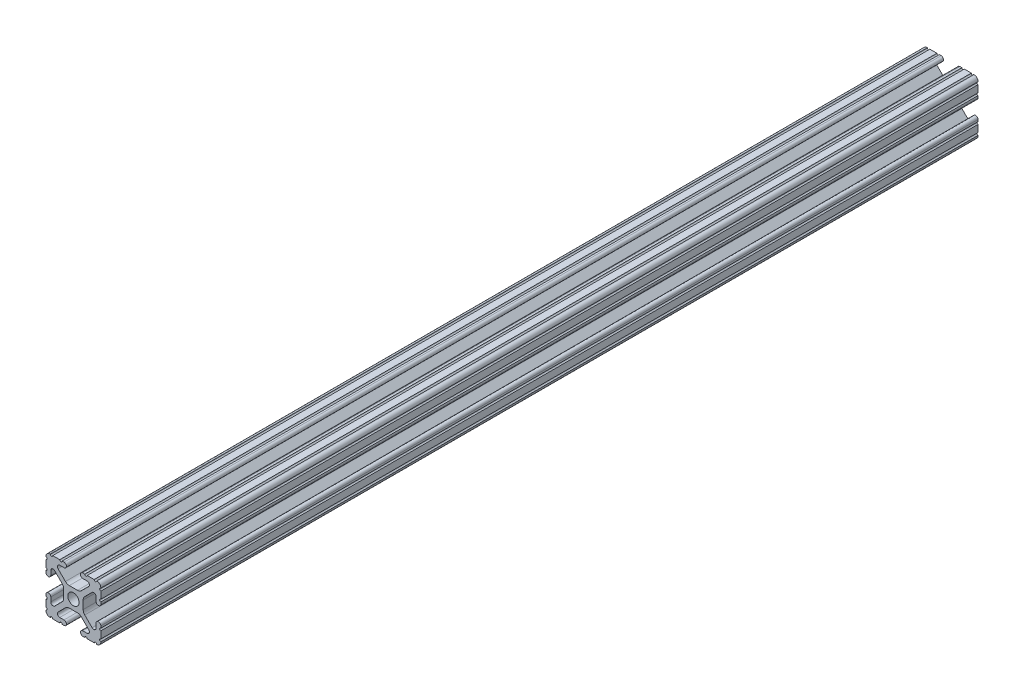
from build123d import *

# Parameters (mm, degrees)
SKETCH3_W                = 25.4
SKETCH3_H                = 25.4
BOSS_EXTRUDE1_DEPTH      = 203.2
BOSS_EXTRUDE1_DEPTH_BACK = 203.2
SKETCH4_R                = 2.6035
CUT_EXTRUDE1_DEPTH       = 407.4
CUT_EXTRUDE2_DEPTH       = 407.4
FILLET1_R                = 2.54
FILLET2_R                = 1.778


with BuildPart() as part:
    # Sketch3 → Boss-Extrude1 (new body, two sides)
    with BuildSketch(Plane.XY) as boss_extrude1_sk:
        Rectangle(SKETCH3_W, SKETCH3_H)
    extrude(amount=BOSS_EXTRUDE1_DEPTH)
    extrude(boss_extrude1_sk.sketch, amount=-BOSS_EXTRUDE1_DEPTH_BACK)

    # Sketch4 → Cut-Extrude1 (cut, through all)
    with BuildSketch(Plane.XY.offset(203.2)):
        with BuildLine():
            Line((3.2512, 12.7), (-3.2512, 12.7))
            Line((-3.2512, 12.7), (-3.2512, 10.4902))
            Line((-3.2512, 10.4902), (-6.348478019, 10.4902))
            ThreePointArc((-6.348478019, 10.4902), (-7.335478831, 9.830707141), (-7.103895736, 8.666460301))
            Line((-7.103895736, 8.666460301), (-2.958635435, 4.5212))
            Line((-2.958635435, 4.5212), (2.958635435, 4.5212))
            Line((2.958635435, 4.5212), (7.103895736, 8.666460301))
            ThreePointArc((7.103895736, 8.666460301), (7.335478831, 9.830707141), (6.348478019, 10.4902))
            Line((6.348478019, 10.4902), (3.2512, 10.4902))
            Line((3.2512, 10.4902), (3.2512, 12.7))
        make_face()
        with BuildLine():
            Line((12.7, -3.2512), (12.7, 3.2512))
            Line((12.7, 3.2512), (10.4902, 3.2512))
            Line((10.4902, 3.2512), (10.4902, 6.348478019))
            ThreePointArc((10.4902, 6.348478019), (9.830707141, 7.335478831), (8.666460301, 7.103895736))
            Line((8.666460301, 7.103895736), (4.5212, 2.958635435))
            Line((4.5212, 2.958635435), (4.5212, -2.958635435))
            Line((4.5212, -2.958635435), (8.666460301, -7.103895736))
            ThreePointArc((8.666460301, -7.103895736), (9.830707141, -7.335478831), (10.4902, -6.348478019))
            Line((10.4902, -6.348478019), (10.4902, -3.2512))
            Line((10.4902, -3.2512), (12.7, -3.2512))
        make_face()
        with BuildLine():
            Line((-3.2512, -10.4902), (-3.2512, -12.7))
            Line((-3.2512, -12.7), (3.2512, -12.7))
            Line((3.2512, -12.7), (3.2512, -10.4902))
            Line((3.2512, -10.4902), (6.348478019, -10.4902))
            ThreePointArc((6.348478019, -10.4902), (7.335478831, -9.830707141), (7.103895736, -8.666460301))
            Line((7.103895736, -8.666460301), (2.958635435, -4.5212))
            Line((2.958635435, -4.5212), (-2.958635435, -4.5212))
            Line((-2.958635435, -4.5212), (-7.103895736, -8.666460301))
            ThreePointArc((-7.103895736, -8.666460301), (-7.335478831, -9.830707141), (-6.348478019, -10.4902))
            Line((-6.348478019, -10.4902), (-3.2512, -10.4902))
        make_face()
        with BuildLine():
            Line((-10.4902, 3.2512), (-12.7, 3.2512))
            Line((-12.7, 3.2512), (-12.7, -3.2512))
            Line((-12.7, -3.2512), (-10.4902, -3.2512))
            Line((-10.4902, -3.2512), (-10.4902, -6.348478019))
            ThreePointArc((-10.4902, -6.348478019), (-9.830707141, -7.335478831), (-8.666460301, -7.103895736))
            Line((-8.666460301, -7.103895736), (-4.5212, -2.958635435))
            Line((-4.5212, -2.958635435), (-4.5212, 2.958635435))
            Line((-4.5212, 2.958635435), (-8.666460301, 7.103895736))
            ThreePointArc((-8.666460301, 7.103895736), (-9.830707141, 7.335478831), (-10.4902, 6.348478019))
            Line((-10.4902, 6.348478019), (-10.4902, 3.2512))
        make_face()
        Circle(SKETCH4_R)
    extrude(amount=-CUT_EXTRUDE1_DEPTH, mode=Mode.SUBTRACT)

    # Sketch5 → Cut-Extrude2 (cut, through all)
    with BuildSketch(Plane.XY.offset(203.2)):
        with BuildLine():
            ThreePointArc((-11.5951, 3.2512), (-12.376382283, 3.574817717), (-12.7, 4.3561))
            Line((-12.7, 4.3561), (-12.7, 3.2512))
            Line((-12.7, 3.2512), (-11.5951, 3.2512))
        make_face()
        with BuildLine():
            ThreePointArc((-10.4902, 4.3561), (-10.813817717, 3.574817717), (-11.5951, 3.2512))
            Line((-11.5951, 3.2512), (-10.4902, 3.2512))
            Line((-10.4902, 3.2512), (-10.4902, 4.3561))
        make_face()
        with BuildLine():
            Line((-12.7, -3.2512), (-12.7, -4.3561))
            ThreePointArc((-12.7, -4.3561), (-12.376382283, -3.574817717), (-11.5951, -3.2512))
            Line((-11.5951, -3.2512), (-12.7, -3.2512))
        make_face()
        with BuildLine():
            Line((-10.4902, -3.2512), (-11.5951, -3.2512))
            ThreePointArc((-11.5951, -3.2512), (-10.813817717, -3.574817717), (-10.4902, -4.3561))
            Line((-10.4902, -4.3561), (-10.4902, -3.2512))
        make_face()
        with BuildLine():
            Line((-3.2512, -11.595100007), (-3.2512, -10.4902))
            Line((-3.2512, -10.4902), (-4.3561, -10.4902))
            ThreePointArc((-4.3561, -10.4902), (-3.574817715, -10.81381772), (-3.2512, -11.595100007))
        make_face()
        with BuildLine():
            Line((-3.2512, -12.7), (-3.2512, -11.595100007))
            ThreePointArc((-3.2512, -11.595100007), (-3.57481772, -12.376382285), (-4.3561, -12.7))
            Line((-4.3561, -12.7), (-3.2512, -12.7))
        make_face()
        with BuildLine():
            Line((3.2512, -10.4902), (3.2512, -11.5951))
            ThreePointArc((3.2512, -11.5951), (3.574817718, -10.813817717), (4.3561, -10.4902))
            Line((4.3561, -10.4902), (3.2512, -10.4902))
        make_face()
        with BuildLine():
            Line((3.2512, -12.7), (4.3561, -12.7))
            ThreePointArc((4.3561, -12.7), (3.574817717, -12.376382282), (3.2512, -11.5951))
            Line((3.2512, -11.5951), (3.2512, -12.7))
        make_face()
        with BuildLine():
            Line((11.5951, -3.2512), (10.4902, -3.2512))
            Line((10.4902, -3.2512), (10.4902, -4.3561))
            ThreePointArc((10.4902, -4.3561), (10.813817717, -3.574817717), (11.5951, -3.2512))
        make_face()
        with BuildLine():
            Line((12.7, -3.2512), (11.5951, -3.2512))
            ThreePointArc((11.5951, -3.2512), (12.376382283, -3.574817717), (12.7, -4.3561))
            Line((12.7, -4.3561), (12.7, -3.2512))
        make_face()
        with BuildLine():
            Line((10.4902, 3.2512), (11.5951, 3.2512))
            ThreePointArc((11.5951, 3.2512), (10.813817717, 3.574817717), (10.4902, 4.3561))
            Line((10.4902, 4.3561), (10.4902, 3.2512))
        make_face()
        with BuildLine():
            Line((12.7, 3.2512), (12.7, 4.3561))
            ThreePointArc((12.7, 4.3561), (12.376382283, 3.574817717), (11.5951, 3.2512))
            Line((11.5951, 3.2512), (12.7, 3.2512))
        make_face()
        with BuildLine():
            Line((3.2512, 12.7), (3.2512, 11.595099996))
            ThreePointArc((3.2512, 11.595099996), (3.574817716, 12.376382281), (4.3561, 12.7))
            Line((4.3561, 12.7), (3.2512, 12.7))
        make_face()
        with BuildLine():
            Line((3.2512, 11.595099996), (3.2512, 10.4902))
            Line((3.2512, 10.4902), (4.3561, 10.4902))
            ThreePointArc((4.3561, 10.4902), (3.574817719, 10.813817716), (3.2512, 11.595099996))
        make_face()
        with BuildLine():
            Line((-3.2512, 12.7), (-4.3561, 12.7))
            ThreePointArc((-4.3561, 12.7), (-3.574817717, 12.376382283), (-3.2512, 11.5951))
            Line((-3.2512, 11.5951), (-3.2512, 12.7))
        make_face()
        with BuildLine():
            Line((-3.2512, 10.4902), (-3.2512, 11.5951))
            ThreePointArc((-3.2512, 11.5951), (-3.574817717, 10.813817717), (-4.3561, 10.4902))
            Line((-4.3561, 10.4902), (-3.2512, 10.4902))
        make_face()
        with BuildLine():
            ThreePointArc((-12.7, 5.23875), (-12.14755, 5.7912), (-12.7, 6.34365))
            Line((-12.7, 6.34365), (-12.7, 5.23875))
        make_face()
        with BuildLine():
            ThreePointArc((-12.7, 9.60755), (-12.14755, 10.16), (-12.7, 10.71245))
            Line((-12.7, 10.71245), (-12.7, 9.60755))
        make_face()
        with BuildLine():
            ThreePointArc((-10.71245, 12.7), (-10.16, 12.14755), (-9.60755, 12.7))
            Line((-9.60755, 12.7), (-10.71245, 12.7))
        make_face()
        with BuildLine():
            ThreePointArc((-6.34365, 12.7), (-5.7912, 12.14755), (-5.23875, 12.7))
            Line((-5.23875, 12.7), (-6.34365, 12.7))
        make_face()
        with BuildLine():
            Line((6.34365, 12.7), (5.23875, 12.7))
            ThreePointArc((5.23875, 12.7), (5.7912, 12.14755), (6.34365, 12.7))
        make_face()
        with BuildLine():
            Line((10.71245, 12.7), (9.60755, 12.7))
            ThreePointArc((9.60755, 12.7), (10.16, 12.14755), (10.71245, 12.7))
        make_face()
        with BuildLine():
            Line((12.7, 10.71245), (12.7, 9.60755))
            ThreePointArc((12.7, 9.60755), (12.14755, 10.16), (12.7, 10.71245))
        make_face()
        with BuildLine():
            Line((12.7, 6.34365), (12.7, 5.23875))
            ThreePointArc((12.7, 5.23875), (12.14755, 5.7912), (12.7, 6.34365))
        make_face()
        with BuildLine():
            Line((-12.7, -6.34365), (-12.7, -5.23875))
            ThreePointArc((-12.7, -5.23875), (-12.14755, -5.7912), (-12.7, -6.34365))
        make_face()
        with BuildLine():
            Line((-12.7, -10.71245), (-12.7, -9.60755))
            ThreePointArc((-12.7, -9.60755), (-12.14755, -10.16), (-12.7, -10.71245))
        make_face()
        with BuildLine():
            Line((-10.71245, -12.7), (-9.60755, -12.7))
            ThreePointArc((-9.60755, -12.7), (-10.16, -12.14755), (-10.71245, -12.7))
        make_face()
        with BuildLine():
            Line((-6.34365, -12.7), (-5.23875, -12.7))
            ThreePointArc((-5.23875, -12.7), (-5.7912, -12.14755), (-6.34365, -12.7))
        make_face()
        with BuildLine():
            Line((12.7, -10.71245), (12.7, -9.60755))
            ThreePointArc((12.7, -9.60755), (12.14755, -10.16), (12.7, -10.71245))
        make_face()
        with BuildLine():
            Line((12.7, -6.34365), (12.7, -5.23875))
            ThreePointArc((12.7, -5.23875), (12.14755, -5.7912), (12.7, -6.34365))
        make_face()
        with BuildLine():
            Line((10.71245, -12.7), (9.60755, -12.7))
            ThreePointArc((9.60755, -12.7), (10.16, -12.14755), (10.71245, -12.7))
        make_face()
        with BuildLine():
            Line((6.34365, -12.7), (5.23875, -12.7))
            ThreePointArc((5.23875, -12.7), (5.7912, -12.14755), (6.34365, -12.7))
        make_face()
    extrude(amount=-CUT_EXTRUDE2_DEPTH, mode=Mode.SUBTRACT)

    # Fillet1
    fillet1_edges = [part.edges().sort_by_distance(p)[0] for p in [
        (2.958635435, 4.5212, 0),
        (-2.958635435, 4.5212, 0),
        (-2.958635435, -4.5212, 0),
        (2.958635435, -4.5212, 0),
        (4.5212, -2.958635435, 0),
        (4.5212, 2.958635435, 0),
        (-4.5212, 2.958635435, 0),
        (-4.5212, -2.958635435, 0),
    ]]
    fillet(fillet1_edges, radius=FILLET1_R)

    # Fillet2
    fillet2_edges = [part.edges().sort_by_distance(p)[0] for p in [
        (-12.7, 12.7, 0),
        (12.7, 12.7, 0),
        (12.7, -12.7, 0),
        (-12.7, -12.7, 0),
    ]]
    fillet(fillet2_edges, radius=FILLET2_R)


solid = part.part
